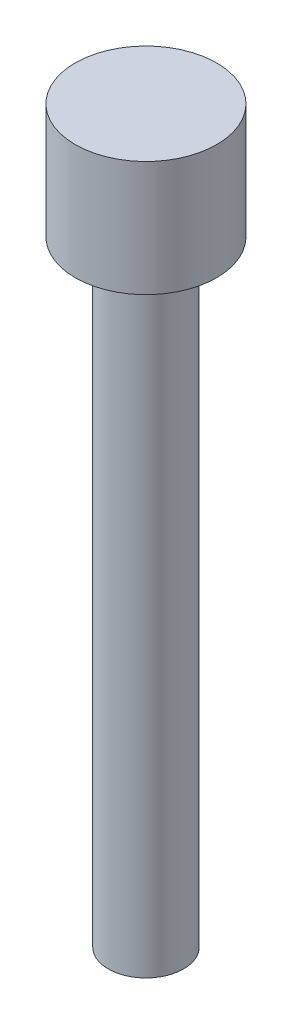
from build123d import *

# Parameters (mm, degrees)
SKETCH1_R           = 1.84
BOSS_EXTRUDE1_DEPTH = 3
SKETCH2_R           = 0.98
BOSS_EXTRUDE2_DEPTH = 16


with BuildPart() as part:
    # Sketch1 → Boss-Extrude1 (new body)
    with BuildSketch(Plane(origin=(0, 0, 0), x_dir=(1, 0, 0), z_dir=(0, 1, 0))):
        Circle(SKETCH1_R)
    extrude(amount=BOSS_EXTRUDE1_DEPTH)

    # Sketch2 → Boss-Extrude2 (add)
    with BuildSketch(Plane.XZ):
        Circle(SKETCH2_R)
    extrude(amount=BOSS_EXTRUDE2_DEPTH)


solid = part.part
